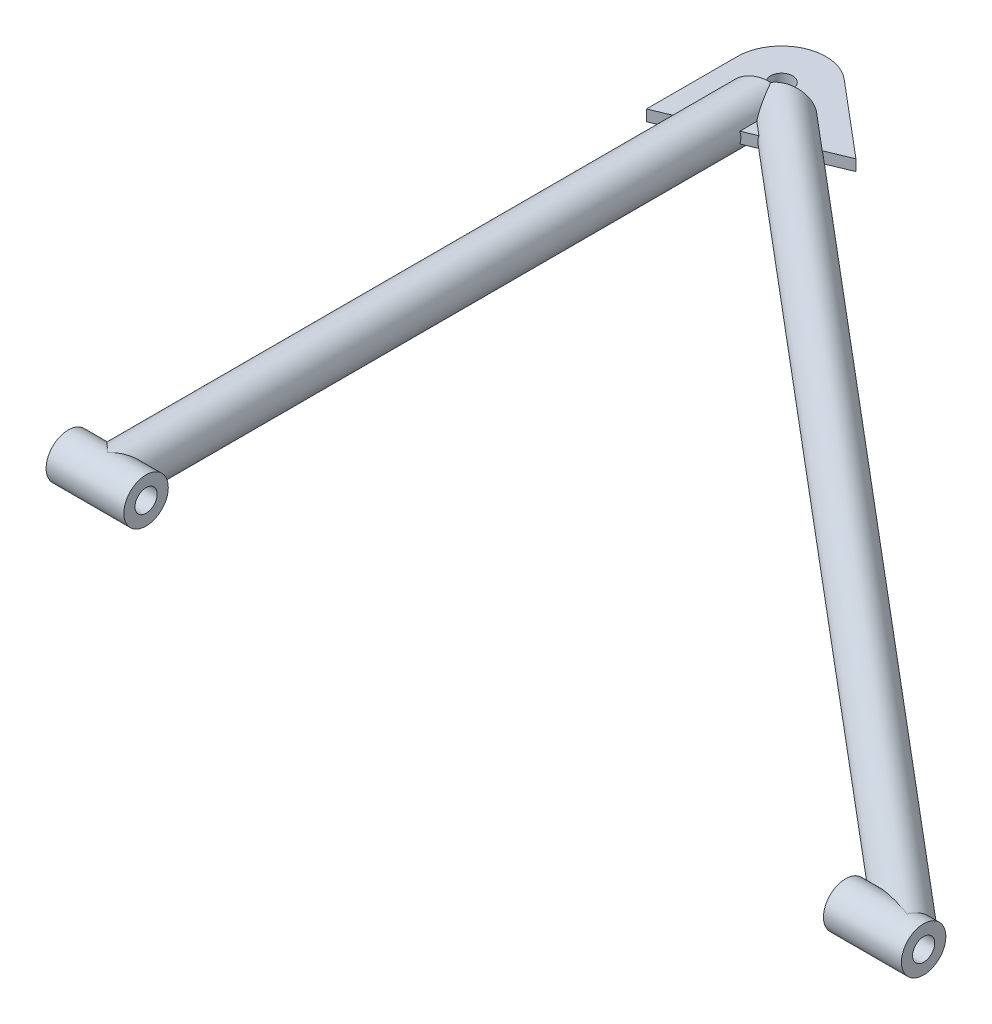
from build123d import *

# Parameters (mm, degrees)
SKETCH11_ON_SEGMENT_1_R         = 12.7
SKETCH11_ON_SEGMENT_1_R_2       = 9.525
STRUCTURAL_MEMBER1_DEPTH        = 425.159349585
SKETCH11_R                      = 12.7
SKETCH11_R_2                    = 9.525
STRUCTURAL_MEMBER1_2_DEPTH      = 598.045513025
STRUCTURAL_MEMBER1_2_DEPTH_BACK = 39.638149585
CUT_EXTRUDE1_DEPTH              = 611.698909876
CUT_EXTRUDE1_DEPTH_BACK         = 611.698909876
BOSS_EXTRUDE1_DEPTH             = 3.175
BOSS_EXTRUDE1_DEPTH_BACK        = 3.175
SKETCH14_W                      = 6.35
SKETCH14_H                      = 15.875
SKETCH16_R                      = 12.7
CUT_EXTRUDE2_DEPTH              = 621.968967697
CUT_EXTRUDE2_DEPTH_BACK         = 621.968967697
SKETCH17_R                      = 12.7
BOSS_EXTRUDE2_DEPTH             = 22.225
BOSS_EXTRUDE2_DEPTH_BACK        = 22.225
SKETCH18_R                      = 12.7
BOSS_EXTRUDE3_DEPTH             = 9.525
BOSS_EXTRUDE3_DEPTH_BACK        = 35.052
SKETCH19_W                      = 6.35
SKETCH19_H                      = 488.95


with BuildPart() as part:
    # Sketch11 on segment 1 (carried to segment 1) → Structural Member1 (new body)
    with BuildSketch(Plane(origin=(0, 0, 0), x_dir=(-1, 0, 0), z_dir=(0, 0, -1))):
        Circle(SKETCH11_ON_SEGMENT_1_R)
        Circle(SKETCH11_ON_SEGMENT_1_R_2, mode=Mode.SUBTRACT)
    extrude(amount=STRUCTURAL_MEMBER1_DEPTH)

    # Structural Member1 mitre 1
    split(bisect_by=Plane(origin=(0, 0, -385.5212), x_dir=(0, -1, 0), z_dir=(-0.906817297, 0, 0.421523891)), keep=Keep.TOP)


with BuildPart() as body_2:
    # Sketch11 → Structural Member1 2 (new, two sides)
    with BuildSketch(Plane(origin=(0, 0, -385.5212), x_dir=(0.6446352185637546, 0, -0.7644903105908277), z_dir=(0.7644903105908278, 0, 0.6446352185637547))) as structural_member1_2_sk:
        Circle(SKETCH11_R)
        Circle(SKETCH11_R_2, mode=Mode.SUBTRACT)
    extrude(amount=STRUCTURAL_MEMBER1_2_DEPTH)
    extrude(structural_member1_2_sk.sketch, amount=-STRUCTURAL_MEMBER1_2_DEPTH_BACK)

    # Structural Member1 2 mitre 1
    split(bisect_by=Plane(origin=(0, 0, -385.5212), x_dir=(0, 1, 0), z_dir=(0.906817297, 0, -0.421523891)), keep=Keep.TOP)


with BuildPart() as part_1:
    add(part.part)

    # Structural Member1 as one body: union body 2
    add(body_2.part)

    # Sketch13 → Cut-Extrude1 (cut, two sides)
    with BuildSketch(Plane(origin=(0, 0, -385.5212), x_dir=(0.3843431928760582, 0, 0.9231902892090218), z_dir=(-0.9231902892090218, 0, 0.3843431928760582))) as cut_extrude1_sk:
        Polygon((12.7, 3.175), (38.1, 3.175), (38.1, -3.175), (12.7, -3.175), (12.7, -12.7), (-30.103915168, -12.7), (-30.103915168, 12.7), (12.7, 12.7), align=None)
    extrude(amount=CUT_EXTRUDE1_DEPTH, mode=Mode.SUBTRACT)
    extrude(cut_extrude1_sk.sketch, amount=-CUT_EXTRUDE1_DEPTH_BACK, mode=Mode.SUBTRACT)

    # Sketch16 → Cut-Extrude2 (cut, two sides)
    with BuildSketch(Plane(origin=(0, 0, 0), x_dir=(0, 0, -1), z_dir=(1, 0, 0))) as cut_extrude2_sk:
        Circle(SKETCH16_R)
    extrude(amount=CUT_EXTRUDE2_DEPTH, mode=Mode.SUBTRACT)
    extrude(cut_extrude2_sk.sketch, amount=-CUT_EXTRUDE2_DEPTH_BACK, mode=Mode.SUBTRACT)


with BuildPart() as body_2_2:
    # Sketch12 → Boss-Extrude1 (new, two sides)
    with BuildSketch(Plane(origin=(0, 0, 0), x_dir=(1, 0, 0), z_dir=(0, 1, 0))) as boss_extrude1_sk:
        with BuildLine():
            Line((16.373734552, 404.939253889), (59.144220595, 368.874229602))
            Line((59.144220595, 368.874229602), (-25.4, 333.676723668))
            Line((-25.4, 333.676723668), (-25.4, 385.5212))
            ThreePointArc((-25.4, 385.5212), (-10.706706832, 408.554359332), (16.373734552, 404.939253889))
        make_face()
    extrude(amount=BOSS_EXTRUDE1_DEPTH)
    extrude(boss_extrude1_sk.sketch, amount=-BOSS_EXTRUDE1_DEPTH_BACK)

    # Sketch14 → 1_2 _0.5_ Diameter Hole1 (revolve, cut)
    with BuildSketch(Plane(origin=(0, 3.175, -385.5212), x_dir=(0, 0, 1), z_dir=(1, 0, 0))):
        with Locations((3.175, 7.9375)):
            Rectangle(SKETCH14_W, SKETCH14_H)
    revolve(axis=Axis((0, 9.525, -385.5212), (0, -1, 0)), mode=Mode.SUBTRACT)


with BuildPart() as body_3:
    # Sketch17 → Boss-Extrude2 (new, two sides)
    with BuildSketch(Plane(origin=(0, 0, 0), x_dir=(0, 0, -1), z_dir=(1, 0, 0))) as boss_extrude2_sk:
        Circle(SKETCH17_R)
    extrude(amount=BOSS_EXTRUDE2_DEPTH)
    extrude(boss_extrude2_sk.sketch, amount=-BOSS_EXTRUDE2_DEPTH_BACK)


with BuildPart() as body_4:
    # Sketch18 → Boss-Extrude3 (new, two sides)
    with BuildSketch(Plane(origin=(457.2, 0, 0), x_dir=(0, 0, -1), z_dir=(1, 0, 0))) as boss_extrude3_sk:
        Circle(SKETCH18_R)
    extrude(amount=BOSS_EXTRUDE3_DEPTH)
    extrude(boss_extrude3_sk.sketch, amount=-BOSS_EXTRUDE3_DEPTH_BACK)


with BuildPart() as f_1_2_0_5_diameter_hole2_tool:
    # Sketch19 → 1_2 _0.5_ Diameter Hole2 (revolve)
    with BuildSketch(Plane(origin=(-22.225, 0, 0), x_dir=(0, 0, 1), z_dir=(0, 1, 0))):
        with Locations((3.175, 244.475)):
            Rectangle(SKETCH19_W, SKETCH19_H)
    revolve(axis=Axis((-28.575, 0, 0), (1, 0, 0)))


with BuildPart() as body_3_1:
    add(body_3.part)

    # 1_2 _0.5_ Diameter Hole2: cut by f_1_2_0_5_diameter_hole2_tool
    add(f_1_2_0_5_diameter_hole2_tool.part, mode=Mode.SUBTRACT)


with BuildPart() as body_4_1:
    add(body_4.part)

    # 1_2 _0.5_ Diameter Hole2: cut by f_1_2_0_5_diameter_hole2_tool
    add(f_1_2_0_5_diameter_hole2_tool.part, mode=Mode.SUBTRACT)


solid = Compound([part_1.part, body_2_2.part, body_3_1.part, body_4_1.part])
